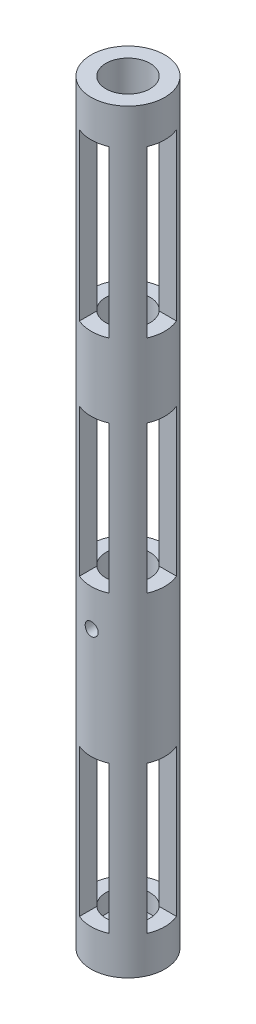
from build123d import *

# Parameters (mm, degrees)
SKETCH1_R               = 12.7
SKETCH1_R_2             = 7.62
BOSS_EXTRUDE1_DEPTH     = 260.35
SKETCH2_R               = 7.62
BOSS_EXTRUDE2_DEPTH     = 6.35
SKETCH3_R               = 2.2479
CUT_EXTRUDE1_DEPTH      = 1
CUT_EXTRUDE1_DEPTH_BACK = 30.21
SKETCH5_W               = 10.16
SKETCH5_H               = 50.8
SKETCH5_H_2             = 57.15
CUT_EXTRUDE5_DEPTH      = 13.7000001
CUT_EXTRUDE5_DEPTH_BACK = 13.7000001
SKETCH8_W               = 10.16
SKETCH8_H               = 50.8
SKETCH8_H_2             = 57.15
CUT_EXTRUDE6_DEPTH      = 13.7000001
CUT_EXTRUDE6_DEPTH_BACK = 13.7000001
SKETCH7_R               = 3.81
CUT_EXTRUDE4_DEPTH      = 7.3500001


with BuildPart() as part:
    # Sketch1 → Boss-Extrude1 (new body)
    with BuildSketch(Plane(origin=(0, 0, 0), x_dir=(1, 0, 0), z_dir=(0, 1, 0))):
        Circle(SKETCH1_R)
        Circle(SKETCH1_R_2, mode=Mode.SUBTRACT)
    extrude(amount=BOSS_EXTRUDE1_DEPTH)

    # Sketch2 → Boss-Extrude2 (add)
    with BuildSketch(Plane.XZ):
        Circle(SKETCH2_R)
    extrude(amount=-BOSS_EXTRUDE2_DEPTH)

    # Sketch3 → Cut-Extrude1 (cut, two sides)
    with BuildSketch(Plane.XY.offset(16.51)) as cut_extrude1_sk:
        with Locations((0, 101.6)):
            Circle(SKETCH3_R)
    extrude(amount=CUT_EXTRUDE1_DEPTH, mode=Mode.SUBTRACT)
    extrude(cut_extrude1_sk.sketch, amount=-CUT_EXTRUDE1_DEPTH_BACK, mode=Mode.SUBTRACT)

    # Sketch5 → Cut-Extrude5 (cut, two sides)
    with BuildSketch(Plane(origin=(0, 0, 0), x_dir=(0, 0, -1), z_dir=(1, 0, 0))) as cut_extrude5_sk:
        with Locations((0, 38.1)):
            Rectangle(SKETCH5_W, SKETCH5_H)
        with Locations((0, 139.7)):
            Rectangle(SKETCH5_W, SKETCH5_H)
        with Locations((0, 219.075)):
            Rectangle(SKETCH5_W, SKETCH5_H_2)
    extrude(amount=CUT_EXTRUDE5_DEPTH, mode=Mode.SUBTRACT)
    extrude(cut_extrude5_sk.sketch, amount=-CUT_EXTRUDE5_DEPTH_BACK, mode=Mode.SUBTRACT)

    # Sketch8 → Cut-Extrude6 (cut, two sides)
    with BuildSketch(Plane.XY) as cut_extrude6_sk:
        with Locations((0, 38.1)):
            Rectangle(SKETCH8_W, SKETCH8_H)
        with Locations((0, 139.7)):
            Rectangle(SKETCH8_W, SKETCH8_H)
        with Locations((0, 219.075)):
            Rectangle(SKETCH8_W, SKETCH8_H_2)
    extrude(amount=CUT_EXTRUDE6_DEPTH, mode=Mode.SUBTRACT)
    extrude(cut_extrude6_sk.sketch, amount=-CUT_EXTRUDE6_DEPTH_BACK, mode=Mode.SUBTRACT)

    # Sketch7 → Cut-Extrude4 (cut, through all)
    with BuildSketch(Plane(origin=(0, 6.35, 0), x_dir=(1, 0, 0), z_dir=(0, 1, 0))):
        Circle(SKETCH7_R)
    extrude(amount=-CUT_EXTRUDE4_DEPTH, mode=Mode.SUBTRACT)


solid = part.part
